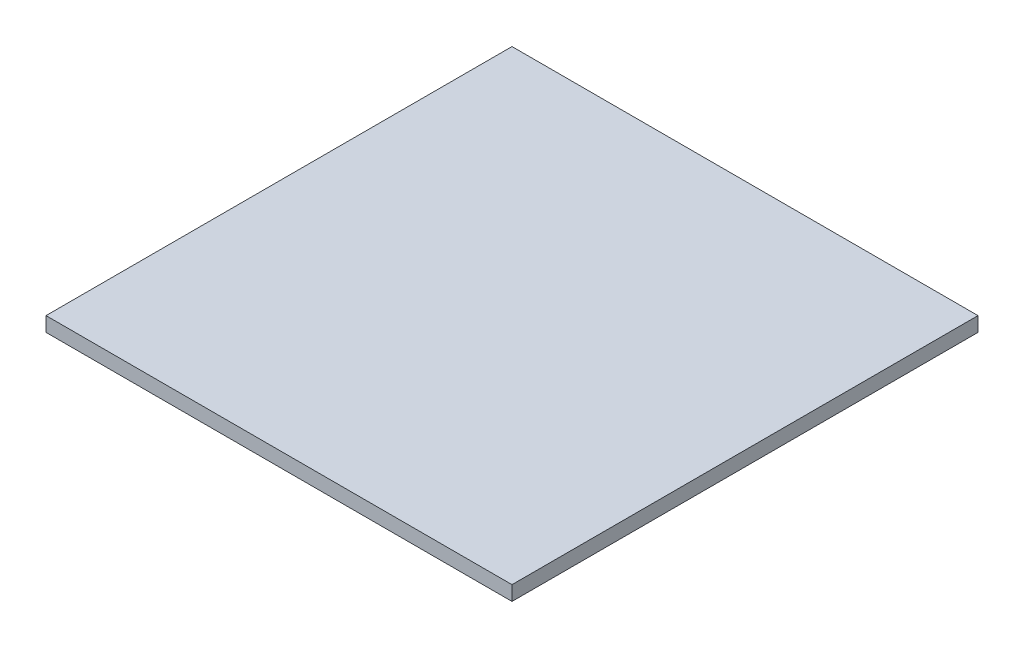
from build123d import *

# Parameters (mm, degrees)
SKETCH1_W           = 203.2
SKETCH1_H           = 203.2
BOSS_EXTRUDE1_DEPTH = 6.35


with BuildPart() as part:
    # Sketch1 → Boss-Extrude1 (new body)
    with BuildSketch(Plane(origin=(0, 0, 0), x_dir=(1, 0, 0), z_dir=(0, 1, 0))):
        with Locations((101.6, 101.6)):
            Rectangle(SKETCH1_W, SKETCH1_H)
    extrude(amount=BOSS_EXTRUDE1_DEPTH)


solid = part.part
